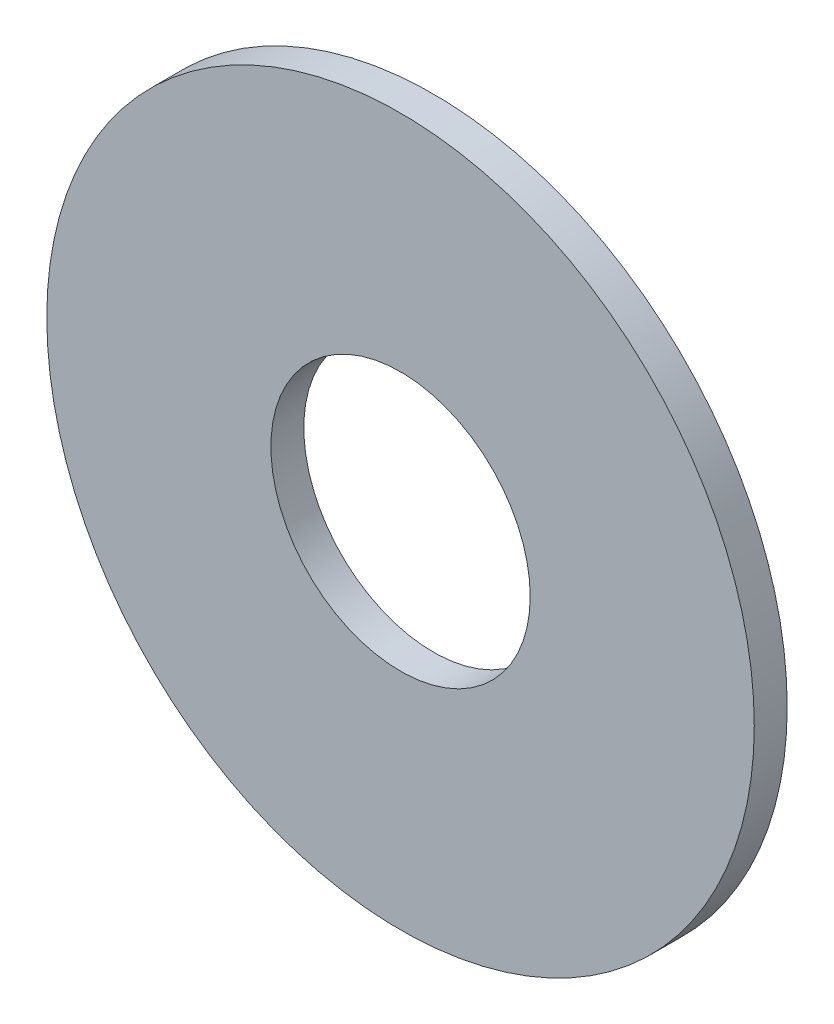
from build123d import *

# Parameters (mm, degrees)
SKETCH3_R                = 8.73125
SKETCH3_R_2              = 3.2004
BOSS_EXTRUDE1_DEPTH      = 0.4064
BOSS_EXTRUDE1_DEPTH_BACK = 0.4064


with BuildPart() as part:
    # Sketch3 → Boss-Extrude1 (new body, two sides)
    with BuildSketch(Plane.XY) as boss_extrude1_sk:
        Circle(SKETCH3_R)
        Circle(SKETCH3_R_2, mode=Mode.SUBTRACT)
    extrude(amount=BOSS_EXTRUDE1_DEPTH)
    extrude(boss_extrude1_sk.sketch, amount=-BOSS_EXTRUDE1_DEPTH_BACK)


solid = part.part
